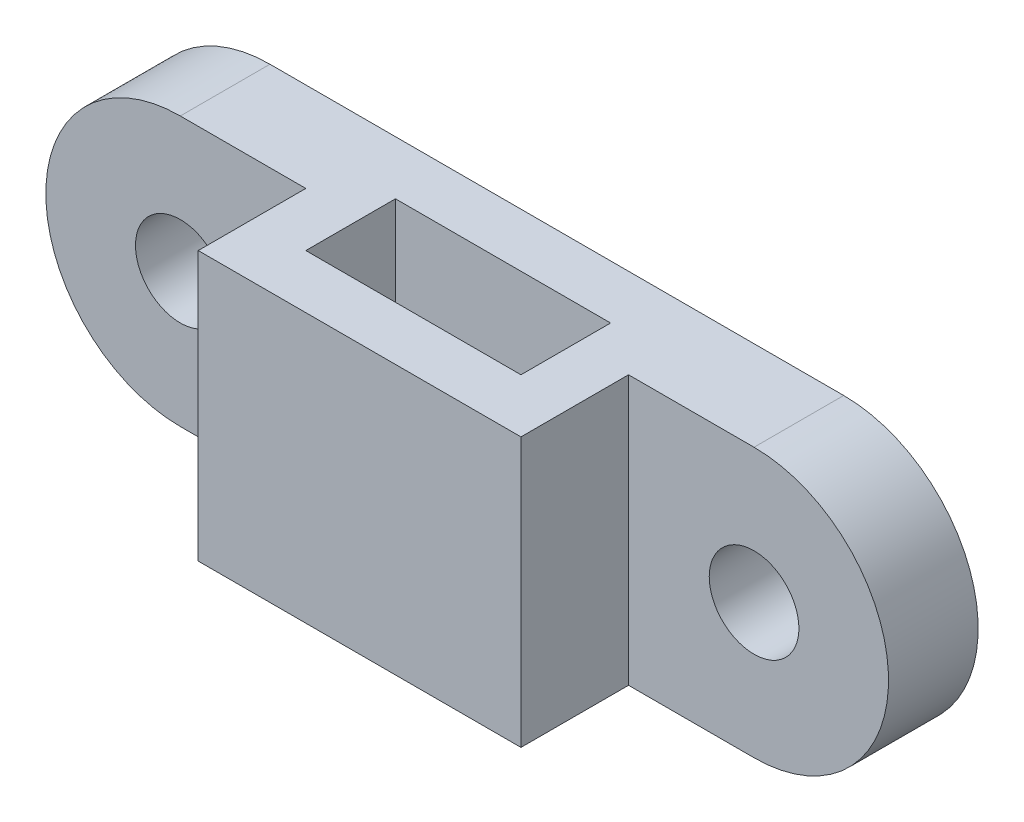
from build123d import *

# Parameters (mm, degrees)
SKETCH1_W           = 18
SKETCH1_H           = 11
SKETCH1_W_2         = 12
SKETCH1_H_2         = 5
BOSS_EXTRUDE1_DEPTH = 15
SKETCH2_R           = 2.5
BOSS_EXTRUDE2_DEPTH = 5
BOSS_EXTRUDE3_DEPTH = 2


with BuildPart() as part:
    # Sketch1 → Boss-Extrude1 (new body)
    with BuildSketch(Plane(origin=(0, 0, 0), x_dir=(1, 0, 0), z_dir=(0, 1, 0))):
        with Locations((6, -2.5)):
            Rectangle(SKETCH1_W, SKETCH1_H)
        with Locations((6, -2.5)):
            Rectangle(SKETCH1_W_2, SKETCH1_H_2, mode=Mode.SUBTRACT)
    extrude(amount=BOSS_EXTRUDE1_DEPTH)

    # Sketch2 → Boss-Extrude2 (add)
    with BuildSketch(Plane(origin=(0, 0, -3), x_dir=(-1, 0, 0), z_dir=(0, 0, -1))):
        with BuildLine():
            ThreePointArc((10, 15), (17.5, 7.5), (10, 0))
            Line((10, 0), (3, 0))
            Line((3, 0), (3, 15))
            Line((3, 15), (10, 15))
        make_face()
        with Locations((10, 7.5)):
            Circle(SKETCH2_R, mode=Mode.SUBTRACT)
        with BuildLine():
            Line((-15, 15), (-22, 15))
            ThreePointArc((-22, 15), (-29.5, 7.5), (-22, 0))
            Line((-22, 0), (-15, 0))
            Line((-15, 0), (-15, 15))
        make_face()
        with Locations((-22, 7.5)):
            Circle(SKETCH2_R, mode=Mode.SUBTRACT)
    extrude(amount=-BOSS_EXTRUDE2_DEPTH)

    # Sketch3 → Boss-Extrude3 (add)
    with BuildSketch(Plane(origin=(0, 5, 0), x_dir=(-1, 0, 0), z_dir=(0, -1, 0))):
        Polygon((-12, -2.828427125), (-12, 0), (-9.171572875, 0), align=None)
        Polygon((0, -2.171572875), (0, -5), (-2.828427125, -5), align=None)
    extrude(amount=-BOSS_EXTRUDE3_DEPTH)


solid = part.part
